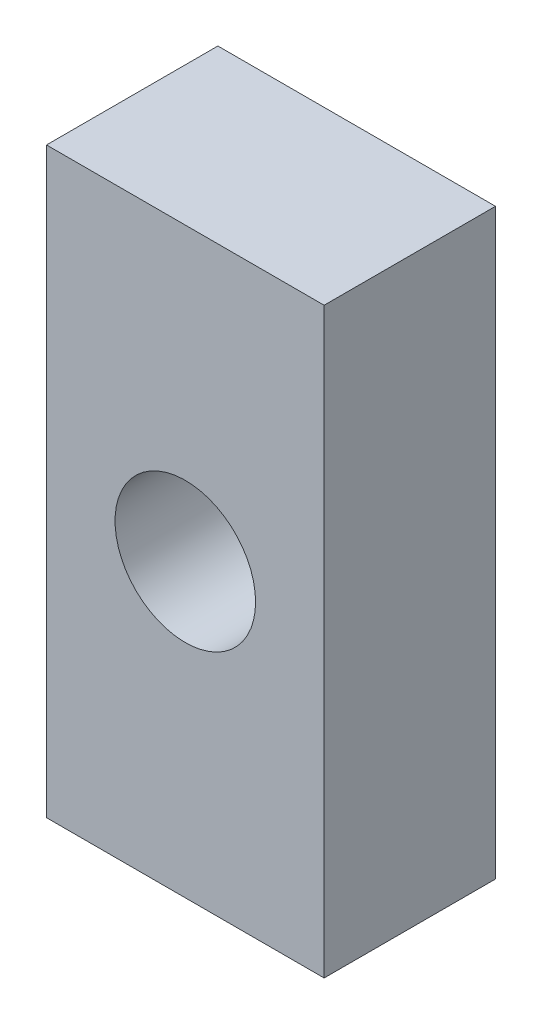
from build123d import *

# Parameters (mm, degrees)
SKETCH1_W           = 8.1
SKETCH1_H           = 17
SKETCH1_R           = 2.05
BOSS_EXTRUDE1_DEPTH = 5


with BuildPart() as part:
    # Sketch1 → Boss-Extrude1 (new body)
    with BuildSketch(Plane.XY):
        with Locations((-14.45, 0)):
            Rectangle(SKETCH1_W, SKETCH1_H)
        with Locations((-14.45, 0)):
            Circle(SKETCH1_R, mode=Mode.SUBTRACT)
    extrude(amount=BOSS_EXTRUDE1_DEPTH)


solid = part.part
